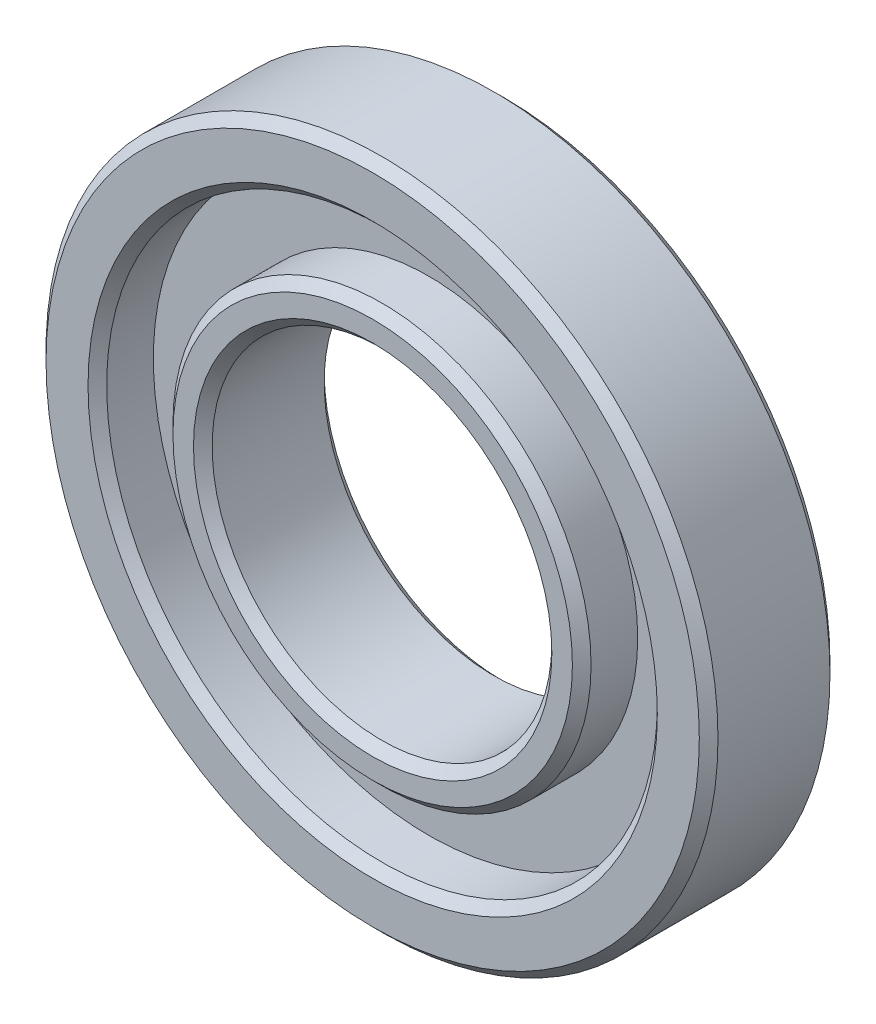
from build123d import *

# Parameters (mm, degrees)
CROQUIS1_R              = 18
CROQUIS1_R_2            = 9.1
SALIENTE_EXTRUIR1_DEPTH = 7
CROQUIS2_R              = 14.75
CROQUIS2_R_2            = 11.2
CORTAR_EXTRUIR1_DEPTH   = 3
CHAFL_N1_SIZE           = 0.5


with BuildPart() as part:
    # Croquis1 → Saliente-Extruir1 (new body)
    with BuildSketch(Plane.XY):
        Circle(CROQUIS1_R)
        Circle(CROQUIS1_R_2, mode=Mode.SUBTRACT)
    extrude(amount=SALIENTE_EXTRUIR1_DEPTH)

    # Croquis2 → Cortar-Extruir1 (cut)
    with BuildSketch(Plane.XY.offset(7)):
        Circle(CROQUIS2_R)
        Circle(CROQUIS2_R_2, mode=Mode.SUBTRACT)
    extrude(amount=-CORTAR_EXTRUIR1_DEPTH, mode=Mode.SUBTRACT)

    # Chaflán1
    chafl_n1_edges = [part.edges().sort_by_distance(p)[0] for p in [
        (-14.75, 0, 7),
        (-11.2, 0, 7),
        (-18, 0, 0),
        (-18, 0, 7),
        (-9.1, 0, 0),
        (-9.1, 0, 7),
    ]]
    chamfer(chafl_n1_edges, length=CHAFL_N1_SIZE)


solid = part.part
